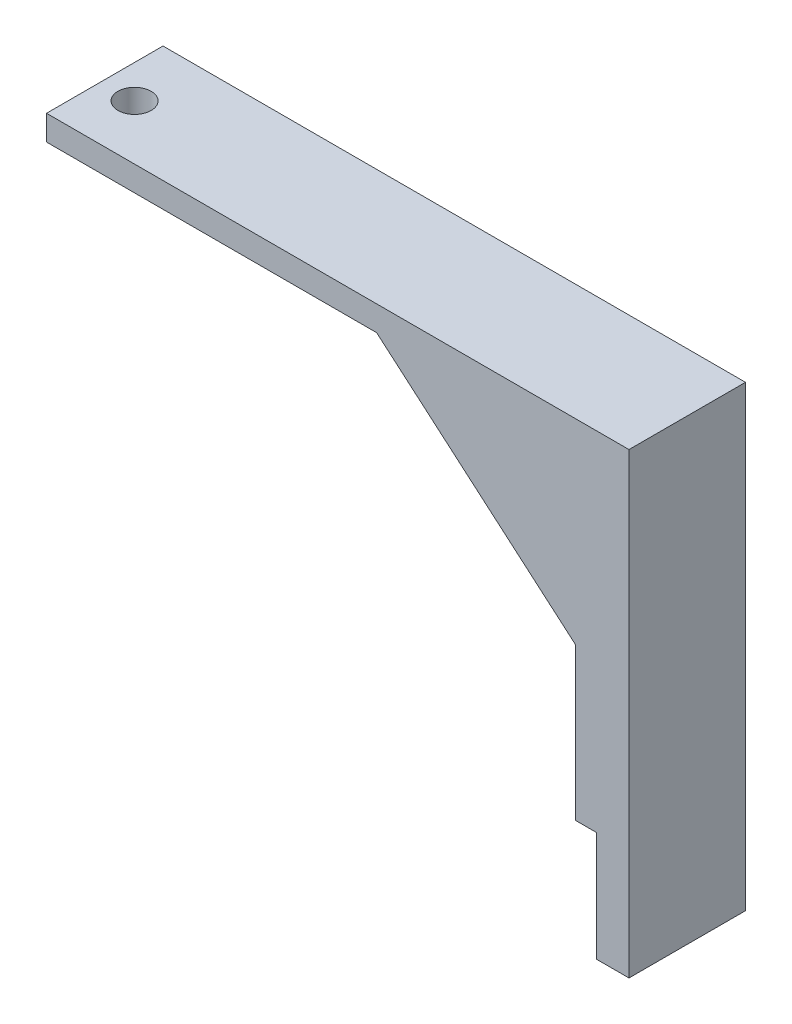
from build123d import *

# Parameters (mm, degrees)
EXTRUDE1_DEPTH = 28
SKETCH2_R      = 4
EXTRUDE2_DEPTH = 28


with BuildPart() as part:
    # Sketch1 → Extrude1 (new body)
    with BuildSketch(Plane.XY):
        Polygon((26.019200203, -56.93280055), (33.825600327, -56.93280055), (33.825600327, 53.06719945), (-106.174399673, 53.06719945), (-106.174399673, 47.06719945), (-26.830398907, 47.06719945), (21.019200203, 5.985600058), (21.019200203, -30.557082965), (26.019200203, -30.557082965), align=None)
    extrude(amount=EXTRUDE1_DEPTH)

    # Sketch2 → Extrude2 (cut)
    with BuildSketch(Plane(origin=(0, 53.06719945, 0), x_dir=(-1, 0, 0), z_dir=(0, 1, 0))):
        with Locations((98.174399673, 14.841787133)):
            Circle(SKETCH2_R)
    extrude(amount=-EXTRUDE2_DEPTH, mode=Mode.SUBTRACT)


solid = part.part
